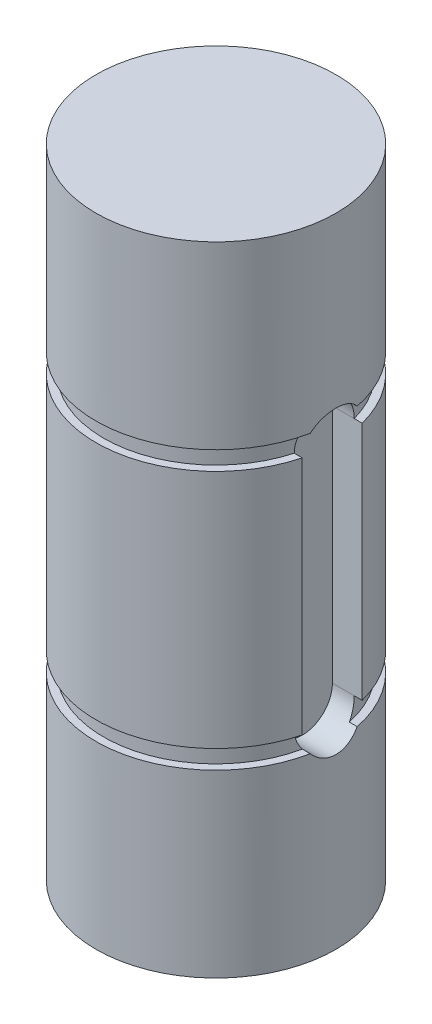
from build123d import *

# Parameters (mm, degrees)
SKETCH1_R           = 6.35
BOSS_EXTRUDE1_DEPTH = 33.7312
SKETCH2_W           = 20.748446766
SKETCH2_H           = 0.9906
SKETCH3_W           = 15.336822943
SKETCH3_H           = 0.9906
CUT_EXTRUDE1_DEPTH  = 1.778


with BuildPart() as part:
    # Sketch1 → Boss-Extrude1 (new body)
    with BuildSketch(Plane(origin=(0, 0, 0), x_dir=(1, 0, 0), z_dir=(0, 1, 0))):
        Circle(SKETCH1_R)
    extrude(amount=BOSS_EXTRUDE1_DEPTH)

    # Sketch2 → Cut-Revolve1 (revolve, cut)
    with BuildSketch(Plane(origin=(0, 0, 0), x_dir=(0, 0, -1), z_dir=(1, 0, 0))):
        with Locations((-16.317823383, 23.7109)):
            Rectangle(SKETCH2_W, SKETCH2_H)
    revolve(axis=Axis((0, 25.517050234, 0), (0, -1, 0)), mode=Mode.SUBTRACT)

    # Sketch3 → Cut-Revolve2 (revolve, cut)
    with BuildSketch(Plane(origin=(0, 0, 0), x_dir=(0, 0, -1), z_dir=(1, 0, 0))):
        with Locations((-13.612011472, 10.0203)):
            Rectangle(SKETCH3_W, SKETCH3_H)
    revolve(axis=Axis((0, 15.810643297, 0), (0, -1, 0)), mode=Mode.SUBTRACT)

    # Sketch4 → Cut-Extrude1 (cut)
    with BuildSketch(Plane(origin=(6.35, 0, 0), x_dir=(0, 0, -1), z_dir=(1, 0, 0))):
        with BuildLine():
            Line((1.5875, 23.2156), (1.5875, 10.5156))
            ThreePointArc((1.5875, 10.5156), (0, 8.9281), (-1.5875, 10.5156))
            Line((-1.5875, 10.5156), (-1.5875, 23.2156))
            ThreePointArc((-1.5875, 23.2156), (0, 24.8031), (1.5875, 23.2156))
        make_face()
    extrude(amount=-CUT_EXTRUDE1_DEPTH, mode=Mode.SUBTRACT)


solid = part.part
